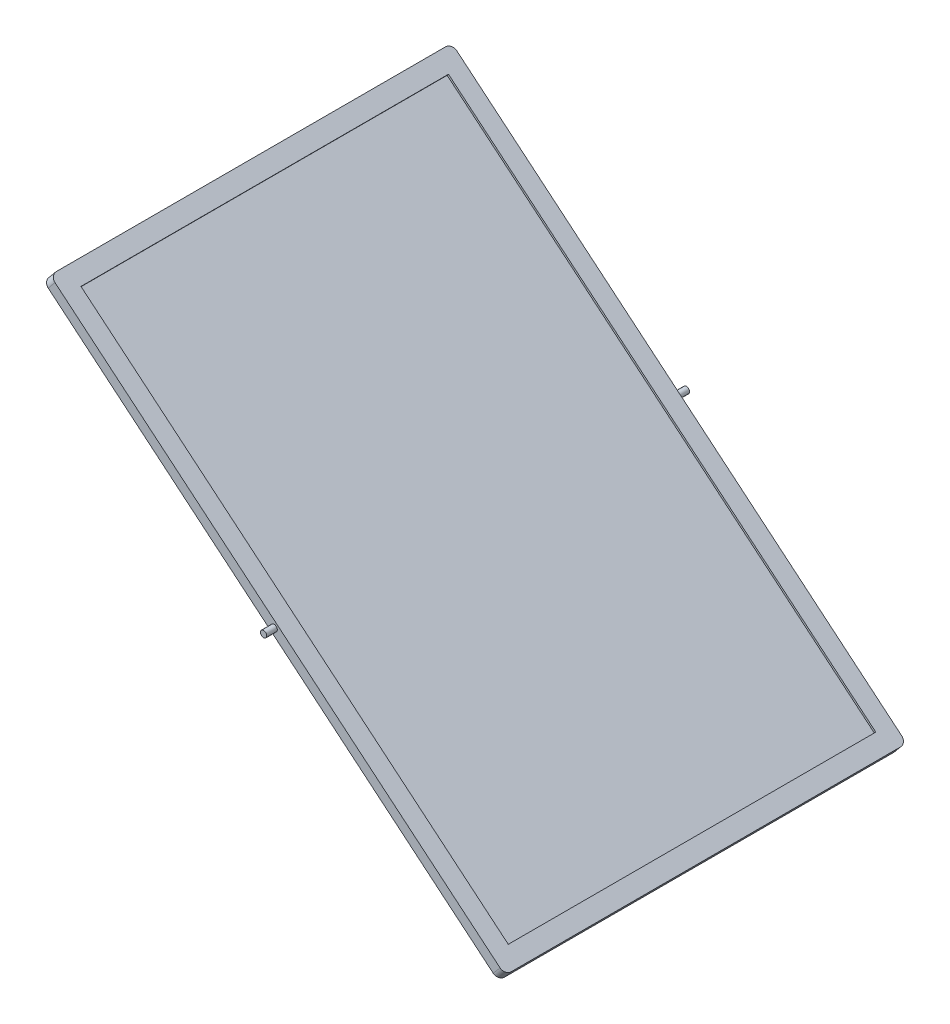
from build123d import *

# Parameters (mm, degrees)
EXTRUDE_1_DEPTH     = 190
FILLET_1_R          = 3
FILLET_2_R          = 3
FILLET_3_R          = 3
FILLET_4_R          = 3
SKETCH_2_W          = 263.076218716
SKETCH_2_H          = 173.825805258
CUT_EXTRUDE_1_DEPTH = 1
SKETCH_3_R          = 1.5
EXTRUDE_2_DEPTH     = 5
SKETCH_4_R          = 1.5
EXTRUDE_3_DEPTH     = 5


with BuildPart() as part:
    # 草图1 → 凸台-拉伸1 (new body)
    with BuildSketch(Plane.XY):
        Polygon((-7.851986906, 22.583577614), (-11.052908905, 18.742471216), (204.049049383, -160.50916069), (207.249971381, -156.668054292), align=None)
    extrude(amount=EXTRUDE_1_DEPTH)

    # 圆角1
    fillet_1_edges = [part.edges().sort_by_distance(p)[0] for p in [
        (205.649510382, -158.588607491, 0),
    ]]
    fillet(fillet_1_edges, radius=FILLET_1_R)

    # 圆角2
    fillet_2_edges = [part.edges().sort_by_distance(p)[0] for p in [
        (205.649510382, -158.588607491, 190),
    ]]
    fillet(fillet_2_edges, radius=FILLET_2_R)

    # 圆角3
    fillet_3_edges = [part.edges().sort_by_distance(p)[0] for p in [
        (-9.452447905, 20.663024415, 190),
    ]]
    fillet(fillet_3_edges, radius=FILLET_3_R)

    # 圆角4
    fillet_4_edges = [part.edges().sort_by_distance(p)[0] for p in [
        (-9.452447905, 20.663024415, 0),
    ]]
    fillet(fillet_4_edges, radius=FILLET_4_R)

    # 草图2 → 切除-拉伸1 (cut)
    with BuildSketch(Plane(origin=(7.888650095, 9.466380114, 0), x_dir=(0.76822128, -0.6401844, 0), z_dir=(0.6401844, 0.76822128, 0))):
        with Locations((119.510282494, -95)):
            Rectangle(SKETCH_2_W, SKETCH_2_H)
    extrude(amount=-CUT_EXTRUDE_1_DEPTH, mode=Mode.SUBTRACT)

    # 草图3 → 凸台-拉伸2 (add)
    with BuildSketch(Plane(origin=(0, 0, 0), x_dir=(-1, 0, 0), z_dir=(0, 0, -1))):
        with Locations(Location((-98.098531238, -68.962791538, 0), (0, 0, 180))):  # turned: the seam where the file's is
            Circle(SKETCH_3_R)
    extrude(amount=EXTRUDE_2_DEPTH)

    # 草图4 → 凸台-拉伸3 (add)
    with BuildSketch(Plane.XY.offset(190)):
        with Locations((98.098531238, -68.962791538)):
            Circle(SKETCH_4_R)
    extrude(amount=EXTRUDE_3_DEPTH)


solid = part.part
